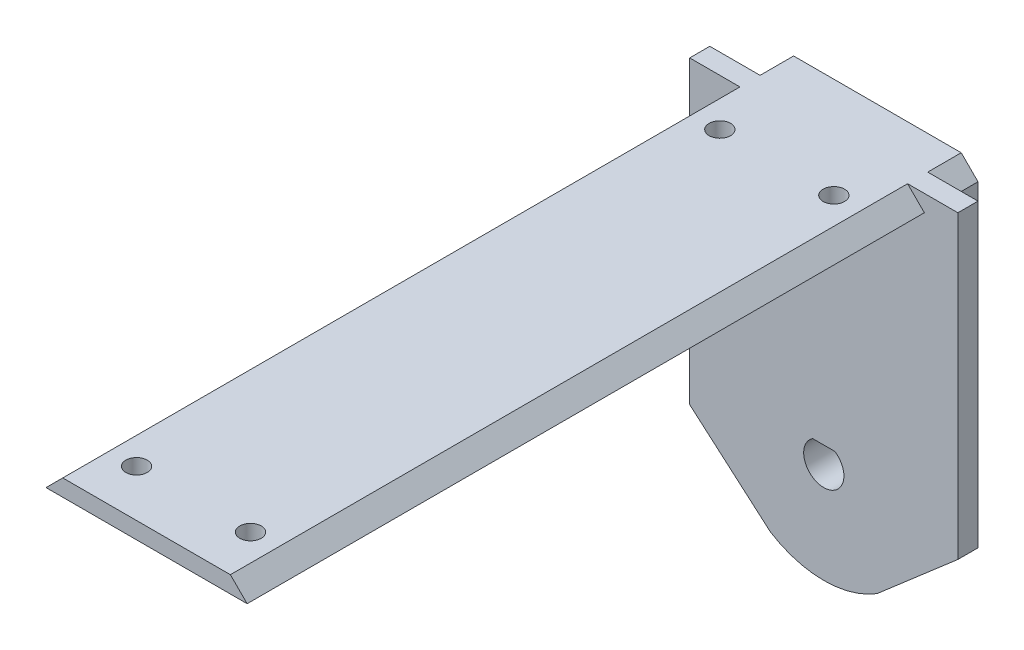
from build123d import *

# Parameters (mm, degrees)
BOSS_EXTRUDE1_DEPTH  = 8
BOSS_EXTRUDE3_DEPTH  = 109
M3_CLEARANCE_SLOT1_D = 3.2
BOSS_EXTRUDE4_DEPTH  = 3


with BuildPart() as part:
    # Sketch1 → Boss-Extrude1 (new body)
    with BuildSketch(Plane.XY):
        with BuildLine():
            Line((15, 33), (-15, 33))
            Line((-15, 33), (-15, -7))
            Line((-15, -7), (-5, -15.660254038))
            ThreePointArc((-5, -15.660254038), (0, -17), (5, -15.660254038))
            Line((5, -15.660254038), (15, -7))
            Line((15, -7), (15, 33))
        make_face()
        with BuildLine():
            Line((1.658312395, -4.5), (-1.658312395, -4.5))
            ThreePointArc((-1.658312395, -4.5), (0, -10), (1.658312395, -4.5))
        make_face(mode=Mode.SUBTRACT)
    extrude(amount=BOSS_EXTRUDE1_DEPTH)

    # Sketch1_5 → Boss-Extrude3 (add)
    with BuildSketch(Plane.XY):
        Polygon((-12.5, 35.5), (12.5, 35.5), (15, 33), (-15, 33), align=None)
    extrude(amount=BOSS_EXTRUDE3_DEPTH)

    # M3 Clearance Slot1 (through all)
    with Locations(Plane(origin=(0, 35.5, 0), x_dir=(1, 0, 0), z_dir=(0, 1, 0))):
        with Locations((-8.5, -15), (8.5, -15), (-8.5, -102), (8.5, -102)):
            Hole(M3_CLEARANCE_SLOT1_D / 2)

    # Sketch6 → Boss-Extrude4 (add)
    with BuildSketch(Plane.XY.offset(8)):
        with BuildLine():
            Line((-20, 35.5), (20, 35.5))
            Line((20, 35.5), (20, 33))
            Line((20, 33), (20, -9.284251259))
            Line((20, -9.284251259), (7.949555075, -19.720242691))
            ThreePointArc((7.949555075, -19.720242691), (0, -22), (-7.949555075, -19.720242691))
            Line((-7.949555075, -19.720242691), (-20, -9.284251259))
            Line((-20, -9.284251259), (-20, 33))
            Line((-20, 33), (-20, 35.5))
        make_face()
        with BuildLine():
            Line((1.658312395, -4.5), (-1.658312395, -4.5))
            ThreePointArc((-1.658312395, -4.5), (0, -10), (1.658312395, -4.5))
        make_face(mode=Mode.SUBTRACT)
    extrude(amount=-BOSS_EXTRUDE4_DEPTH)


solid = part.part
